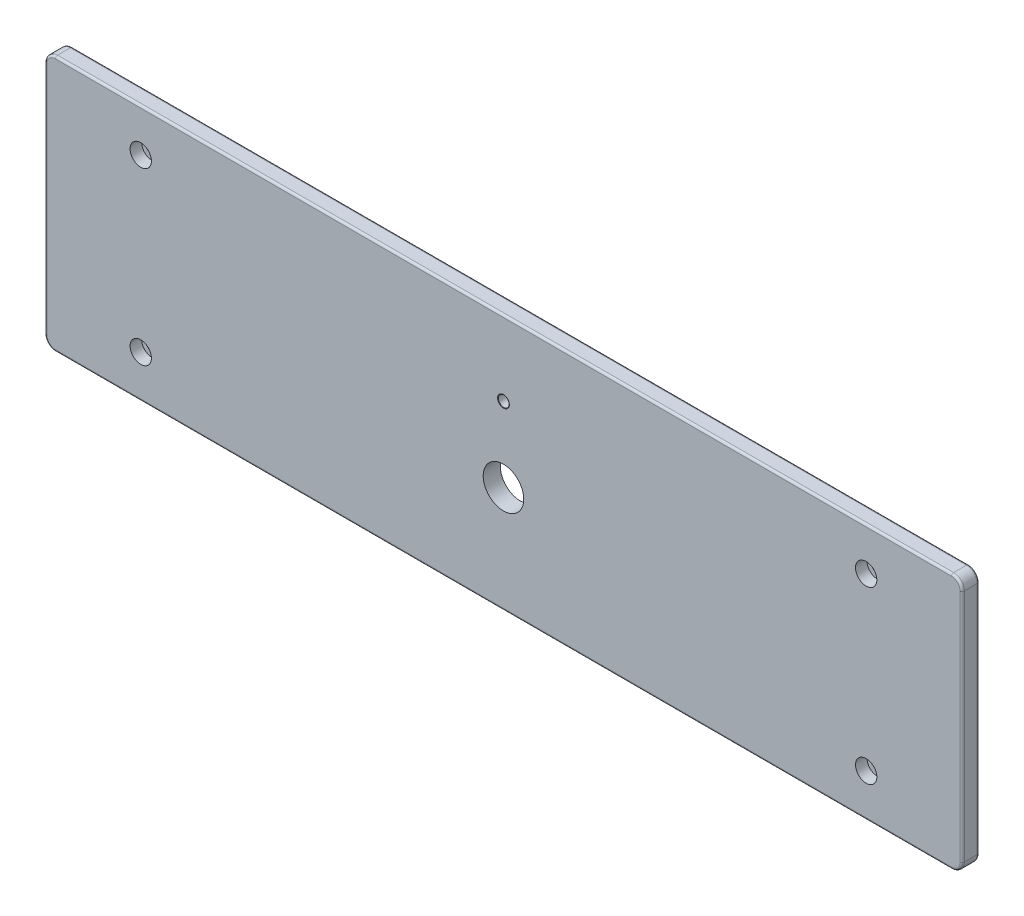
from build123d import *

# Parameters (mm, degrees)
SKETCH1_W                                           = 430
SKETCH1_H                                           = 120
EXTRUDE1_DEPTH                                      = 8
FILLET1_R                                           = 5
FILLET2_R                                           = 1
CBORE_FOR_M5_HEX_SOCKET_HEAD_CAP_SCREW1_D           = 5.5
CBORE_FOR_M5_HEX_SOCKET_HEAD_CAP_SCREW1_CBORE_D     = 10
CBORE_FOR_M5_HEX_SOCKET_HEAD_CAP_SCREW1_CBORE_DEPTH = 5.4
F_5_0_5_DIAMETER_HOLE1_D                            = 5
F_19_0_19_DIAMETER_HOLE1_D                          = 19
CHAMFER1_SIZE                                       = 0.25
CHAMFER1_SIZE2                                      = 0.144337567


with BuildPart() as part:
    # Sketch1 → Extrude1 (new body)
    with BuildSketch(Plane.XY):
        with Locations((215, 60)):
            Rectangle(SKETCH1_W, SKETCH1_H)
    extrude(amount=EXTRUDE1_DEPTH)

    # Fillet1
    fillet1_edges = [part.edges().sort_by_distance(p)[0] for p in [
        (0, 120, 4),
        (430, 120, 4),
        (430, 0, 4),
        (0, 0, 4),
    ]]
    fillet(fillet1_edges, radius=FILLET1_R)

    # Fillet2
    fillet2_edges = [part.edges().sort_by_distance(p)[0] for p in [
        (215, 0, 0),
        (215, 0, 8),
        (0, 60, 0),
        (215, 120, 0),
        (430, 60, 0),
        (1.464466094, 118.535533906, 0),
        (428.535533906, 118.535533906, 0),
        (428.535533906, 1.464466094, 0),
        (1.464466094, 1.464466094, 0),
        (0, 60, 8),
        (430, 60, 8),
        (215, 120, 8),
        (1.464466094, 118.535533906, 8),
        (428.535533906, 118.535533906, 8),
        (428.535533906, 1.464466094, 8),
        (1.464466094, 1.464466094, 8),
    ]]
    fillet(fillet2_edges, radius=FILLET2_R)

    # CBORE for M5 Hex Socket Head Cap Screw1 (through all)
    with Locations(Plane(origin=(45, 100, 8), x_dir=(1, 0, 0), z_dir=(0, 0, 1))):
        with Locations((0, 0), (0, -80), (340, -80), (340, 0)):
            CounterBoreHole(CBORE_FOR_M5_HEX_SOCKET_HEAD_CAP_SCREW1_D / 2, CBORE_FOR_M5_HEX_SOCKET_HEAD_CAP_SCREW1_CBORE_D / 2, CBORE_FOR_M5_HEX_SOCKET_HEAD_CAP_SCREW1_CBORE_DEPTH)

    # Ø5.0 (5) Diameter Hole1 (through all)
    with Locations(Plane(origin=(215, 85, 8), x_dir=(1, 0, 0), z_dir=(0, 0, 1))):
        with Locations((0, 0)):
            Hole(F_5_0_5_DIAMETER_HOLE1_D / 2)

    # Ø19.0 (19) Diameter Hole1 (through all)
    with Locations(Plane(origin=(215, 50, 8), x_dir=(1, 0, 0), z_dir=(0, 0, 1))):
        with Locations((0, 0)):
            Hole(F_19_0_19_DIAMETER_HOLE1_D / 2)

    # Chamfer1
    chamfer1_edges = [part.edges().sort_by_distance(p)[0] for p in [
        (217.5, 85, 8),
    ]]
    chamfer1_side = [part.faces().sort_by_distance(p)[0] for p in [
        (215, 60.047007724, 8),
    ]]
    chamfer(chamfer1_edges, length=CHAMFER1_SIZE, length2=CHAMFER1_SIZE2, reference=chamfer1_side[0])


solid = part.part
